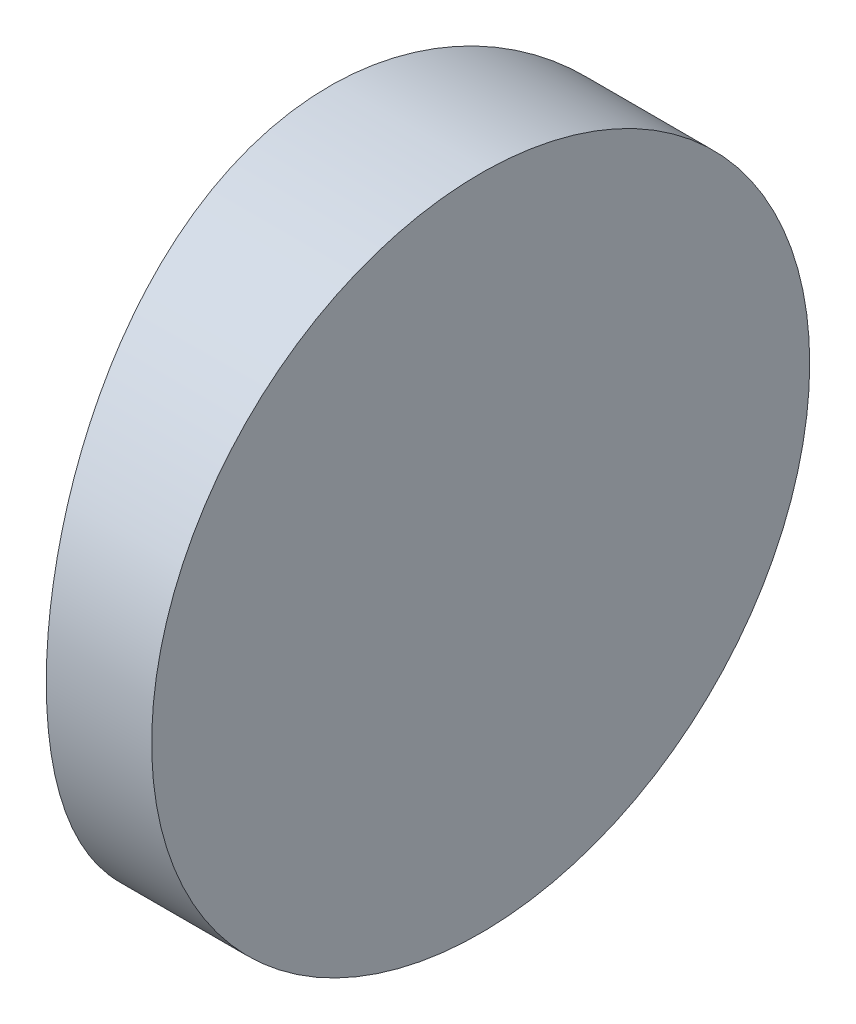
from build123d import *

# Parameters (mm, degrees)
EXTRUDE_1_DEPTH     = 12.5
CUT_EXTRUDE_8_DEPTH = 12.7


with BuildPart() as part:
    # 草图1 → 凸台-拉伸1 (new body)
    with BuildSketch(Plane(origin=(0, 0, 0), x_dir=(1, 0, 0), z_dir=(0, 1, 0))):
        with BuildLine():
            Line((-17.706581631, 6.25), (-15.704795665, 6.25))
            Line((-15.704795665, 6.25), (-15.704795665, -6.25))
            Line((-15.704795665, -6.25), (-17.706581631, -6.25))
            ThreePointArc((-17.706581631, -6.25), (-18.574795665, 0), (-17.706581631, 6.25))
        make_face()
    extrude(amount=EXTRUDE_1_DEPTH)

    # 草图2 → 切除-拉伸8 (cut)
    with BuildSketch(Plane(origin=(-15.704795665, 0, 0), x_dir=(0, 0, -1), z_dir=(1, 0, 0))):
        with BuildLine():
            Line((-6.25, 12.5), (-6.25, 6.25))
            ThreePointArc((-6.25, 6.25), (-4.419417382, 10.669417382), (0, 12.5))
            Line((0, 12.5), (-6.25, 12.5))
        make_face()
        with BuildLine():
            ThreePointArc((0, 12.5), (4.419417382, 10.669417382), (6.25, 6.25))
            Line((6.25, 6.25), (6.25, 12.5))
            Line((6.25, 12.5), (0, 12.5))
        make_face()
        with BuildLine():
            ThreePointArc((6.25, 6.25), (4.419417382, 1.830582618), (0, 0))
            Line((0, 0), (6.25, 0))
            Line((6.25, 0), (6.25, 6.25))
        make_face()
        with BuildLine():
            Line((-6.25, 6.25), (-6.25, 0))
            Line((-6.25, 0), (0, 0))
            ThreePointArc((0, 0), (-4.419417382, 1.830582618), (-6.25, 6.25))
        make_face()
    extrude(amount=-CUT_EXTRUDE_8_DEPTH, mode=Mode.SUBTRACT)


solid = part.part
